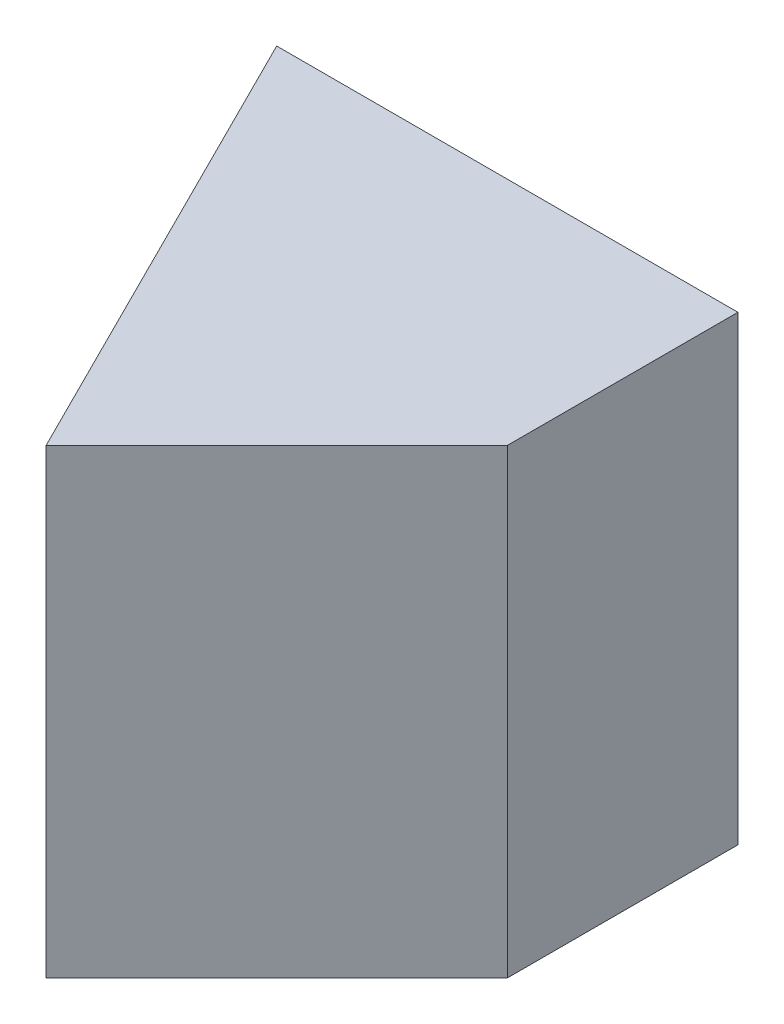
from build123d import *

# Parameters (mm, degrees)
SKETCH1_W           = 20
SKETCH1_H           = 20
BOSS_EXTRUDE1_DEPTH = 20
CUT_EXTRUDE1_DEPTH  = 20
CUT_EXTRUDE2_DEPTH  = 20


with BuildPart() as part:
    # Sketch1 → Boss-Extrude1 (new body)
    with BuildSketch(Plane.XY):
        with Locations((10, 10)):
            Rectangle(SKETCH1_W, SKETCH1_H)
    extrude(amount=BOSS_EXTRUDE1_DEPTH)

    # Sketch2 → Cut-Extrude1 (cut)
    with BuildSketch(Plane(origin=(0, 20, 0), x_dir=(1, 0, 0), z_dir=(0, 1, 0))):
        Polygon((0, 0), (10, -20), (0, -20), align=None)
    extrude(amount=-CUT_EXTRUDE1_DEPTH, mode=Mode.SUBTRACT)

    # Sketch3 → Cut-Extrude2 (cut)
    with BuildSketch(Plane(origin=(0, 20, 0), x_dir=(1, 0, 0), z_dir=(0, 1, 0))):
        Polygon((20, -20), (20, -10), (10, -20), align=None)
    extrude(amount=-CUT_EXTRUDE2_DEPTH, mode=Mode.SUBTRACT)


solid = part.part
